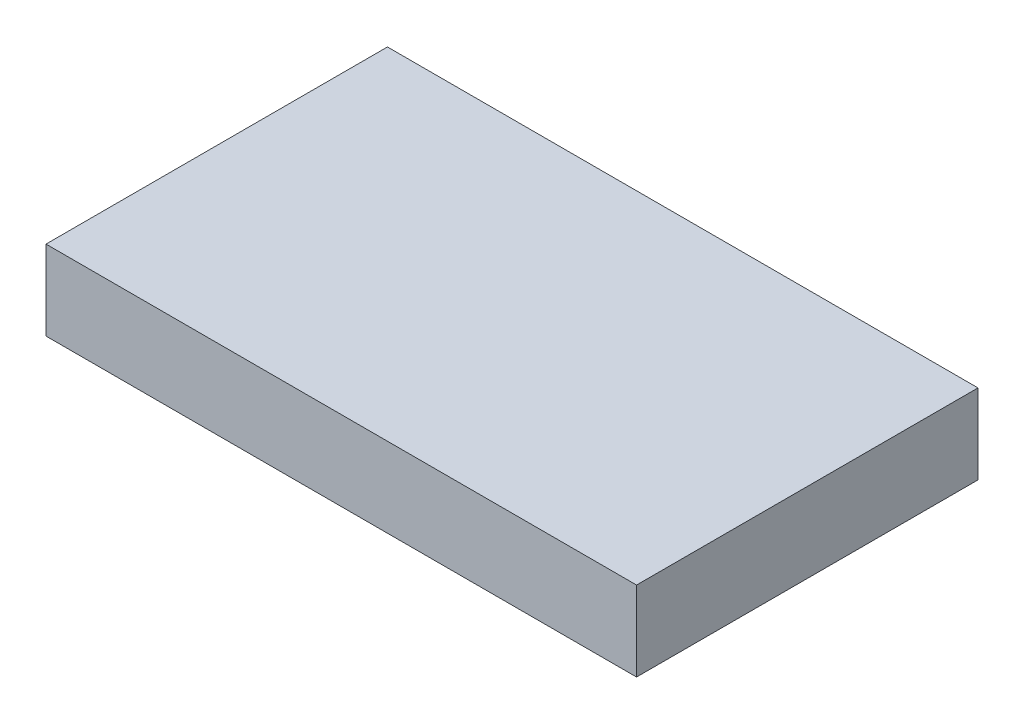
from build123d import *

# Parameters (mm, degrees)
SKETCH1_W           = 80.772
SKETCH1_H           = 46.7
BOSS_EXTRUDE1_DEPTH = 10.9


with BuildPart() as part:
    # Sketch1 → Boss-Extrude1 (new body)
    with BuildSketch(Plane(origin=(0, 0, 0), x_dir=(1, 0, 0), z_dir=(0, 1, 0))):
        with Locations((8.989690383, -30.386237136)):
            Rectangle(SKETCH1_W, SKETCH1_H)
    extrude(amount=BOSS_EXTRUDE1_DEPTH)


solid = part.part
